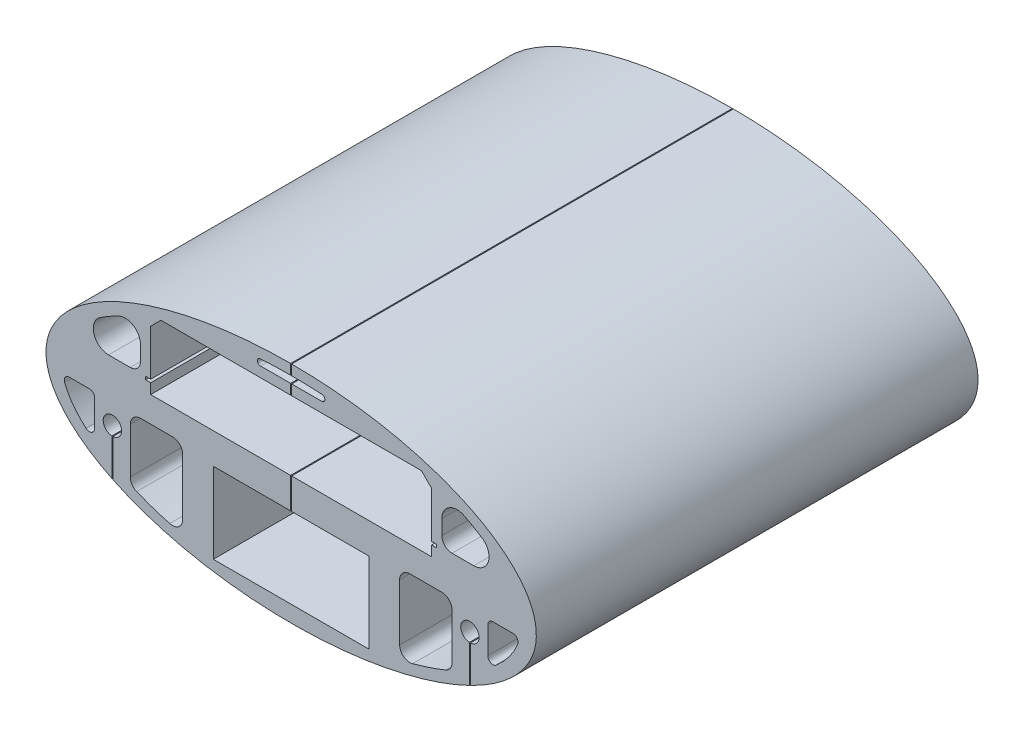
from build123d import *

# Parameters (mm, degrees)
SKETCH1_RX               = 240
SKETCH1_RY               = 110
BOSS_EXTRUDE1_DEPTH      = 432.44
CUT_EXTRUDE5_DEPTH       = 433.44
SKETCH13_W               = 152.4
SKETCH13_H               = 78.9
CUT_EXTRUDE7_DEPTH       = 433.44
SKETCH12_R               = 9
CUT_EXTRUDE8_DEPTH       = 433.44
SKETCH14_W               = 1
SKETCH14_H               = 45.520413792
SKETCH14_H_2             = 125
CUT_EXTRUDE9_DEPTH       = 1
CUT_EXTRUDE9_DEPTH_BACK  = 433.44
CUT_EXTRUDE10_DEPTH      = 1.0000001
CUT_EXTRUDE10_DEPTH_BACK = 433.4400001
FILLET1_R                = 15
FILLET2_R                = 10
FILLET3_R                = 5
FILLET4_R                = 3
CHAMFER1_SIZE            = 10


with BuildPart() as part:
    # Sketch1 → Boss-Extrude1 (new body)
    with BuildSketch(Plane.XY):
        with Locations((0, 0)):
            Ellipse(SKETCH1_RX, SKETCH1_RY)
    extrude(amount=-BOSS_EXTRUDE1_DEPTH)

    # Sketch10 → Cut-Extrude5 (cut, through all)
    with BuildSketch(Plane.XY):
        Polygon((-137.5, 83.1), (137.5, 83.1), (137.5, 28.1), (142.5, 28.1), (142.5, 25.1), (137.5, 25.1), (137.5, 15.1), (-137.5, 15.1), (-137.5, 25.1), (-142.5, 25.1), (-142.5, 28.1), (-137.5, 28.1), align=None)
    extrude(amount=-CUT_EXTRUDE5_DEPTH, mode=Mode.SUBTRACT)

    # Sketch13 → Cut-Extrude7 (cut, through all)
    with BuildSketch(Plane.XY):
        with Locations((0, -54.45)):
            Rectangle(SKETCH13_W, SKETCH13_H)
    extrude(amount=-CUT_EXTRUDE7_DEPTH, mode=Mode.SUBTRACT)

    # Sketch12 → Cut-Extrude8 (cut, through all)
    with BuildSketch(Plane.XY):
        with Locations((175, -30)):
            Circle(SKETCH12_R)
        with Locations((-175, -30)):
            Circle(SKETCH12_R)
    extrude(amount=-CUT_EXTRUDE8_DEPTH, mode=Mode.SUBTRACT)

    # Sketch14 → Cut-Extrude9 (cut, two sides)
    with BuildSketch(Plane.XY) as cut_extrude9_sk:
        with Locations((175, -52.760206896)):
            Rectangle(SKETCH14_W, SKETCH14_H)
        with Locations((-175, -52.760206896)):
            Rectangle(SKETCH14_W, SKETCH14_H)
        with Locations((0, 47.5)):
            Rectangle(SKETCH14_W, SKETCH14_H_2)
    extrude(amount=CUT_EXTRUDE9_DEPTH, mode=Mode.SUBTRACT)
    extrude(cut_extrude9_sk.sketch, amount=-CUT_EXTRUDE9_DEPTH_BACK, mode=Mode.SUBTRACT)

    # Sketch15 → Cut-Extrude10 (cut, two sides)
    with BuildSketch(Plane.XY) as cut_extrude10_sk:
        with BuildLine():
            Line((147.5, 75.514694834), (147.5, 28.1))
            Line((147.5, 28.1), (215.934247805, 28.1))
            add(Edge.make_bspline(
                [(215.934247805, 28.1), (197.375081401, 56.271413469), (147.5, 75.514694834)],
                knots=[3.426428588, 3.426428588, 3.426428588, 3.997470903, 3.997470903, 3.997470903], degree=2, weights=[1, 0.959514995, 1]))
        make_face()
        with BuildLine():
            Line((106.2, -88.159854809), (106.2, -10))
            Line((106.2, -10), (157.5, -10))
            Line((157.5, -10), (157.5, -71.414284285))
            add(Edge.make_bspline(
                [(106.2, -88.159854809), (134.541688555, -81.415904905), (157.5, -71.414284285)],
                knots=[2.062354337, 2.062354337, 2.062354337, 2.346193823, 2.346193823, 2.346193823], degree=2, weights=[1, 0.989946285, 1]))
        make_face()
        with BuildLine():
            Line((192.5, -51.771101143), (192.5, -10))
            Line((192.5, -10), (223.872173349, -10))
            add(Edge.make_bspline(
                [(192.5, -51.771101143), (218.793394961, -32.459203075), (223.872173349, -10)],
                knots=[2.597419317, 2.597419317, 2.597419317, 3.041425232, 3.041425232, 3.041425232], degree=2, weights=[1, 0.975458387, 1]))
        make_face()
        with BuildLine():
            Line((-82.129314955, 93.1), (82.129314955, 93.1))
            add(Edge.make_bspline(
                [(82.129314955, 93.1), (0, 107.411385607), (-82.129314955, 93.1)],
                knots=[4.338735578, 4.338735578, 4.338735578, 5.086042382, 5.086042382, 5.086042382], degree=2, weights=[1, 0.931, 1]))
        make_face()
        with BuildLine():
            Line((-106.2, -88.159854809), (-106.2, -10))
            Line((-106.2, -10), (-157.5, -10))
            Line((-157.5, -10), (-157.5, -71.414284285))
            add(Edge.make_bspline(
                [(-157.5, -71.414284285), (-134.541688555, -81.415904905), (-106.2, -88.159854809)],
                knots=[0.79539883, 0.79539883, 0.79539883, 1.079238317, 1.079238317, 1.079238317], degree=2, weights=[1, 0.989946285, 1]))
        make_face()
        with BuildLine():
            Line((-192.5, -51.771101143), (-192.5, -10))
            Line((-192.5, -10), (-223.872173349, -10))
            add(Edge.make_bspline(
                [(-223.872173349, -10), (-218.793394961, -32.459203075), (-192.5, -51.771101143)],
                knots=[0.100167421, 0.100167421, 0.100167421, 0.544173337, 0.544173337, 0.544173337], degree=2, weights=[1, 0.975458387, 1]))
        make_face()
        with BuildLine():
            Line((-147.5, 28.1), (-215.934247805, 28.1))
            add(Edge.make_bspline(
                [(-147.5, 75.514694834), (-197.375081401, 56.271413469), (-215.934247805, 28.1)],
                knots=[5.427307058, 5.427307058, 5.427307058, 5.998349373, 5.998349373, 5.998349373], degree=2, weights=[1, 0.959514995, 1]))
            Line((-147.5, 75.514694834), (-147.5, 28.1))
        make_face()
    extrude(amount=CUT_EXTRUDE10_DEPTH, mode=Mode.SUBTRACT)
    extrude(cut_extrude10_sk.sketch, amount=-CUT_EXTRUDE10_DEPTH_BACK, mode=Mode.SUBTRACT)

    # Fillet1
    fillet1_edges = [part.edges().sort_by_distance(p)[0] for p in [
        (215.934247805, 28.1, -216.22),
        (147.5, 75.514694834, -216.22),
        (-215.934247805, 28.1, -216.22),
        (-147.5, 75.514694834, -216.22),
    ]]
    fillet(fillet1_edges, radius=FILLET1_R)

    # Fillet2
    fillet2_edges = [part.edges().sort_by_distance(p)[0] for p in [
        (147.5, 28.1, -216.22),
        (-147.5, 28.1, -216.22),
        (157.5, -71.414284285, -216.22),
        (106.2, -10, -216.22),
        (157.5, -10, -216.22),
        (-157.5, -71.414284285, -216.22),
        (-106.2, -10, -216.22),
        (-157.5, -10, -216.22),
        (106.2, -88.159854809, -216.22),
        (-106.2, -88.159854809, -216.22),
    ]]
    fillet(fillet2_edges, radius=FILLET2_R)

    # Fillet3
    fillet3_edges = [part.edges().sort_by_distance(p)[0] for p in [
        (192.5, -51.771101143, -216.22),
        (192.5, -10, -216.22),
        (223.872173349, -10, -216.22),
        (-192.5, -10, -216.22),
        (-192.5, -51.771101143, -216.22),
        (-223.872173349, -10, -216.22),
    ]]
    fillet(fillet3_edges, radius=FILLET3_R)

    # Fillet4
    fillet4_edges = [part.edges().sort_by_distance(p)[0] for p in [
        (-82.129314955, 93.1, -216.22),
        (82.129314955, 93.1, -216.22),
    ]]
    fillet(fillet4_edges, radius=FILLET4_R)

    # Chamfer1
    chamfer1_edges = [part.edges().sort_by_distance(p)[0] for p in [
        (-137.5, 83.1, -216.22),
        (137.5, 83.1, -216.22),
    ]]
    chamfer(chamfer1_edges, length=CHAMFER1_SIZE)


solid = part.part
